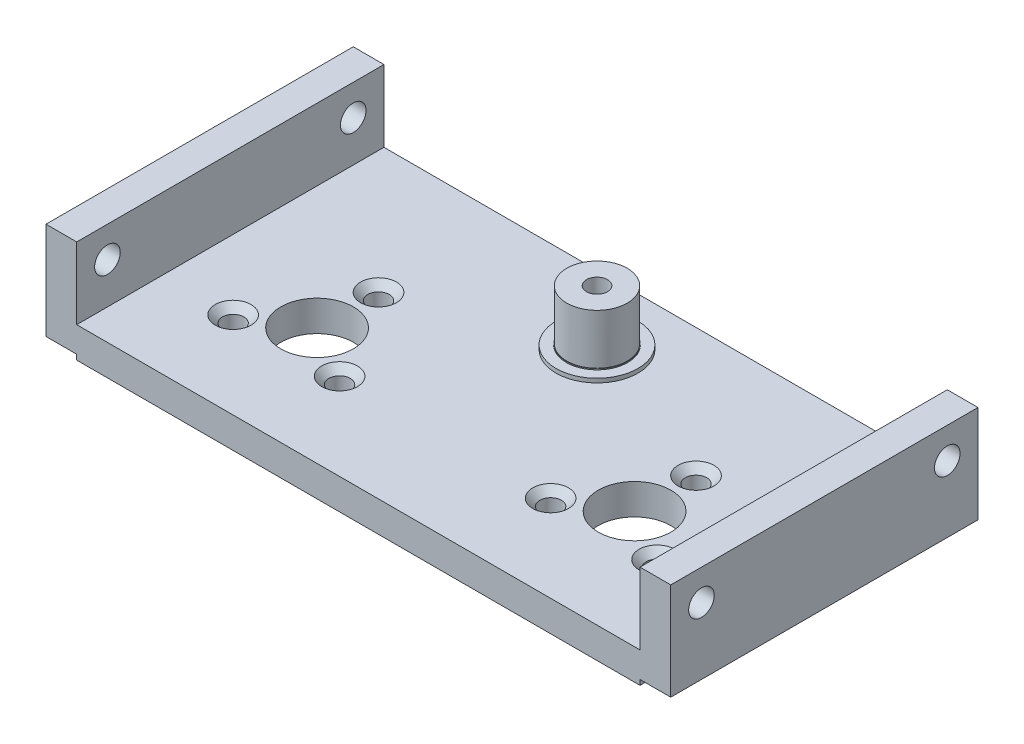
from build123d import *

# Parameters (mm, degrees)
SKETCH1_W                                       = 55
SKETCH1_H                                       = 30
BOSS_EXTRUDE1_DEPTH                             = 3
SKETCH2_R                                       = 2.95
BOSS_EXTRUDE2_DEPTH                             = 4.9
SKETCH8_R                                       = 3.55
CUT_EXTRUDE2_DEPTH                              = 6
SKETCH10_W                                      = 3
SKETCH10_H                                      = 30
BOSS_EXTRUDE3_DEPTH                             = 6.5
BOSS_EXTRUDE3_DEPTH_BACK                        = 3
SKETCH11_W                                      = 3
SKETCH11_H                                      = 30
BOSS_EXTRUDE4_DEPTH                             = 6.5
BOSS_EXTRUDE4_DEPTH_BACK                        = 3
TAP_DRILL_FOR_M3X0_5_TAP1_AT_2_COUNT            = 2
TAP_DRILL_FOR_M3X0_5_TAP1_AT_2_PITCH            = 24
TAP_DRILL_FOR_M2_5X0_45_TAP2_D                  = 2.05
TAP_DRILL_FOR_M2_5X0_45_TAP2_DEPTH              = 6
TAP_DRILL_FOR_M2_5X0_45_TAP2_TIP                = 0.615882
SKETCH18_R                                      = 1.05
CUT_EXTRUDE4_DEPTH                              = 10
CIRPATTERN2_COUNT                               = 3
MIRROR3_COPY_1_SKETCH_R                         = 1.05
MIRROR3_COPY_1_DEPTH                            = 10
MIRROR3_COPY_2_SKETCH_R                         = 1.05
MIRROR3_COPY_2_DEPTH                            = 10
SKETCH21_W                                      = 55
SKETCH21_H                                      = 30
SKETCH21_R                                      = 4
CUT_EXTRUDE7_DEPTH                              = 0.5
SKETCH23_R                                      = 4
SKETCH23_R_2                                    = 3
CUT_EXTRUDE8_DEPTH                              = 0.1
CSK_FOR_M2_FLAT_HEAD_MACHINE_SCREW1_D           = 2.1
CSK_FOR_M2_FLAT_HEAD_MACHINE_SCREW1_DEPTH       = 9.5
CSK_FOR_M2_FLAT_HEAD_MACHINE_SCREW1_CSINK_D     = 3.5
CSK_FOR_M2_FLAT_HEAD_MACHINE_SCREW1_CSINK_ANGLE = 90
CSK_FOR_M2_FLAT_HEAD_MACHINE_SCREW1_TIP         = 0.630904
SKETCH25_W                                      = 55
SKETCH25_H                                      = 30
SKETCH25_R                                      = 3.55
SKETCH25_R_2                                    = 1.05
BOSS_EXTRUDE6_DEPTH                             = 0.5


with BuildPart() as part:
    # Sketch1 → Boss-Extrude1 (new body)
    with BuildSketch(Plane(origin=(0, 0, 0), x_dir=(1, 0, 0), z_dir=(0, 1, 0))):
        with Locations((27.5, 16)):
            Rectangle(SKETCH1_W, SKETCH1_H)
    extrude(amount=BOSS_EXTRUDE1_DEPTH)

    # Sketch2 → Boss-Extrude2 (add)
    with BuildSketch(Plane(origin=(0, 3, 0), x_dir=(1, 0, 0), z_dir=(0, 1, 0))):
        with Locations((27.5, 24.3)):
            Circle(SKETCH2_R)
    extrude(amount=BOSS_EXTRUDE2_DEPTH)

    # Sketch8 → Cut-Extrude2 (cut)
    with BuildSketch(Plane(origin=(0, 3, 0), x_dir=(1, 0, 0), z_dir=(0, 1, 0))):
        with Locations((43, 12.46784)):
            Circle(SKETCH8_R)
    cut_extrude2 = extrude(amount=-CUT_EXTRUDE2_DEPTH, mode=Mode.SUBTRACT)

    # Mirror1: Cut-Extrude2 across plane
    add(cut_extrude2.mirror(Plane(origin=(27.5, 0, 0), x_dir=(0, 0, 1), z_dir=(1, 0, 0))), mode=Mode.SUBTRACT)

    # Sketch10 → Boss-Extrude3 (add, two sides)
    with BuildSketch(Plane(origin=(0, 3, 0), x_dir=(1, 0, 0), z_dir=(0, 1, 0))) as boss_extrude3_sk:
        with Locations((56.5, 16)):
            Rectangle(SKETCH10_W, SKETCH10_H)
    extrude(amount=BOSS_EXTRUDE3_DEPTH)
    extrude(boss_extrude3_sk.sketch, amount=-BOSS_EXTRUDE3_DEPTH_BACK)

    # Sketch11 → Boss-Extrude4 (add, two sides)
    with BuildSketch(Plane(origin=(0, 3, 0), x_dir=(1, 0, 0), z_dir=(0, 1, 0))) as boss_extrude4_sk:
        with Locations((-1.5, 16)):
            Rectangle(SKETCH11_W, SKETCH11_H)
    extrude(amount=BOSS_EXTRUDE4_DEPTH)
    extrude(boss_extrude4_sk.sketch, amount=-BOSS_EXTRUDE4_DEPTH_BACK)

    # Sketch12 → Tap Drill for M3x0.5 Tap1 (revolve, cut)
    with BuildSketch(Plane(origin=(-3, 6.5, -28), x_dir=(0, 0, 1), z_dir=(0, 1, 0))):
        Polygon((0, 0), (0, 10.751076), (1.25, 10), (1.25, 0), align=None)
    tap_drill_for_m3x0_5_tap1 = revolve(axis=Axis((-9.35, 6.5, -28), (1, 0, 0)), mode=Mode.SUBTRACT)

    # Tap Drill for M3x0.5 Tap1 at 2: Tap Drill for M3x0.5 Tap1 ×2
    with Locations(*[(0, 0, i * TAP_DRILL_FOR_M3X0_5_TAP1_AT_2_PITCH) for i in range(1, TAP_DRILL_FOR_M3X0_5_TAP1_AT_2_COUNT)]):
        add(tap_drill_for_m3x0_5_tap1, mode=Mode.SUBTRACT)

    # Mirror2: Tap Drill for M3x0.5 Tap1 across plane
    add(tap_drill_for_m3x0_5_tap1.mirror(Plane(origin=(27.5, 0, 0), x_dir=(0, 0, 1), z_dir=(1, 0, 0))), mode=Mode.SUBTRACT)

    # Mirror2 copy 1 sketch → Mirror2 copy 1 (revolve, cut)
    with BuildSketch(Plane(origin=(58, 6.5, -4), x_dir=(0, 0, 1), z_dir=(0, 1, 0))):
        Polygon((0, 0), (0, -10.751076), (1.25, -10), (1.25, 0), align=None)
    revolve(axis=Axis((64.35, 6.5, -4), (1, 0, 0)), mode=Mode.SUBTRACT)

    # Tap Drill for M2.5x0.45 Tap2
    with Locations(Plane(origin=(0, 7.9, 0), x_dir=(1, 0, 0), z_dir=(0, 1, 0))):
        with Locations((27.5, 24.3)):
            Hole(TAP_DRILL_FOR_M2_5X0_45_TAP2_D / 2, depth=TAP_DRILL_FOR_M2_5X0_45_TAP2_DEPTH)
            with Locations((0, 0, -(TAP_DRILL_FOR_M2_5X0_45_TAP2_DEPTH + TAP_DRILL_FOR_M2_5X0_45_TAP2_TIP / 2))):  # 118° drill point
                Cone(0, TAP_DRILL_FOR_M2_5X0_45_TAP2_D / 2, TAP_DRILL_FOR_M2_5X0_45_TAP2_TIP, mode=Mode.SUBTRACT)

    # Sketch18 → Cut-Extrude4 (cut)
    with BuildSketch(Plane(origin=(0, 3, 0), x_dir=(1, 0, 0), z_dir=(0, 1, 0))):
        with Locations((12, 18.46784)):
            Circle(SKETCH18_R)
    cut_extrude4 = extrude(amount=-CUT_EXTRUDE4_DEPTH, mode=Mode.SUBTRACT)

    # CirPattern2: Cut-Extrude4 ×3 about axis
    cirpattern2_axis = Axis((12, 0, -12.46784), (0, 1, 0))
    for i in range(1, CIRPATTERN2_COUNT):
        add(cut_extrude4.rotate(cirpattern2_axis, i * 360 / CIRPATTERN2_COUNT), mode=Mode.SUBTRACT)

    # Mirror3: Cut-Extrude4 across plane
    add(cut_extrude4.mirror(Plane(origin=(27.5, 0, 0), x_dir=(0, 0, 1), z_dir=(1, 0, 0))), mode=Mode.SUBTRACT)

    # Mirror3 copy 1 sketch → Mirror3 copy 1 (cut)
    with BuildSketch(Plane(origin=(26.202533, 3, -8.309456), x_dir=(0.5, 0, -0.866025), z_dir=(0, 1, 0))):
        with Locations((12, -18.46784)):
            Circle(MIRROR3_COPY_1_SKETCH_R)
    extrude(amount=-MIRROR3_COPY_1_DEPTH, mode=Mode.SUBTRACT)

    # Mirror3 copy 2 sketch → Mirror3 copy 2 (cut)
    with BuildSketch(Plane(origin=(47.797467, 3, -29.094065), x_dir=(0.5, 0, 0.866025), z_dir=(0, 1, 0))):
        with Locations((12, -18.46784)):
            Circle(MIRROR3_COPY_2_SKETCH_R)
    extrude(amount=-MIRROR3_COPY_2_DEPTH, mode=Mode.SUBTRACT)

    # Sketch21 → Cut-Extrude7 (cut)
    with BuildSketch(Plane(origin=(0, 3, 0), x_dir=(1, 0, 0), z_dir=(0, 1, 0))):
        with Locations((27.5, 16)):
            Rectangle(SKETCH21_W, SKETCH21_H)
        with Locations((27.5, 24.3)):
            Circle(SKETCH21_R, mode=Mode.SUBTRACT)
    extrude(amount=-CUT_EXTRUDE7_DEPTH, mode=Mode.SUBTRACT)

    # Sketch23 → Cut-Extrude8 (cut)
    with BuildSketch(Plane(origin=(0, 3, 0), x_dir=(1, 0, 0), z_dir=(0, 1, 0))):
        with Locations((27.5, 24.3)):
            Circle(SKETCH23_R)
        with Locations((27.5, 24.3)):
            Circle(SKETCH23_R_2, mode=Mode.SUBTRACT)
    extrude(amount=-CUT_EXTRUDE8_DEPTH, mode=Mode.SUBTRACT)

    # CSK for M2 Flat Head Machine Screw1
    with Locations(Plane(origin=(43, 2.5, -18.46784), x_dir=(0, 0, 1), z_dir=(0, 1, 0))):
        with Locations((0, 0), (9, 5.196152), (9, -5.196152), (9, -25.803848), (0, -31), (9, -36.196152)):
            CounterSinkHole(CSK_FOR_M2_FLAT_HEAD_MACHINE_SCREW1_D / 2, CSK_FOR_M2_FLAT_HEAD_MACHINE_SCREW1_CSINK_D / 2, depth=CSK_FOR_M2_FLAT_HEAD_MACHINE_SCREW1_DEPTH, counter_sink_angle=CSK_FOR_M2_FLAT_HEAD_MACHINE_SCREW1_CSINK_ANGLE)
            with Locations((0, 0, -(CSK_FOR_M2_FLAT_HEAD_MACHINE_SCREW1_DEPTH + CSK_FOR_M2_FLAT_HEAD_MACHINE_SCREW1_TIP / 2))):  # 118° drill point
                Cone(0, CSK_FOR_M2_FLAT_HEAD_MACHINE_SCREW1_D / 2, CSK_FOR_M2_FLAT_HEAD_MACHINE_SCREW1_TIP, mode=Mode.SUBTRACT)

    # Sketch25 → Boss-Extrude6 (add)
    with BuildSketch(Plane(origin=(0, 0, 0), x_dir=(-1, 0, 0), z_dir=(0, -1, 0))):
        with Locations((-27.5, 16)):
            Rectangle(SKETCH25_W, SKETCH25_H)
        with Locations((-43, 12.46784)):
            Circle(SKETCH25_R, mode=Mode.SUBTRACT)
        with Locations((-48.196152, 9.46784)):
            Circle(SKETCH25_R_2, mode=Mode.SUBTRACT)
        with Locations((-43, 18.46784)):
            Circle(SKETCH25_R_2, mode=Mode.SUBTRACT)
        with Locations((-37.803848, 9.46784)):
            Circle(SKETCH25_R_2, mode=Mode.SUBTRACT)
        with Locations((-12, 12.46784)):
            Circle(SKETCH25_R, mode=Mode.SUBTRACT)
        with Locations((-17.196152, 9.46784)):
            Circle(SKETCH25_R_2, mode=Mode.SUBTRACT)
        with Locations((-12, 18.46784)):
            Circle(SKETCH25_R_2, mode=Mode.SUBTRACT)
        with Locations((-6.803848, 9.46784)):
            Circle(SKETCH25_R_2, mode=Mode.SUBTRACT)
    extrude(amount=BOSS_EXTRUDE6_DEPTH)


solid = part.part
